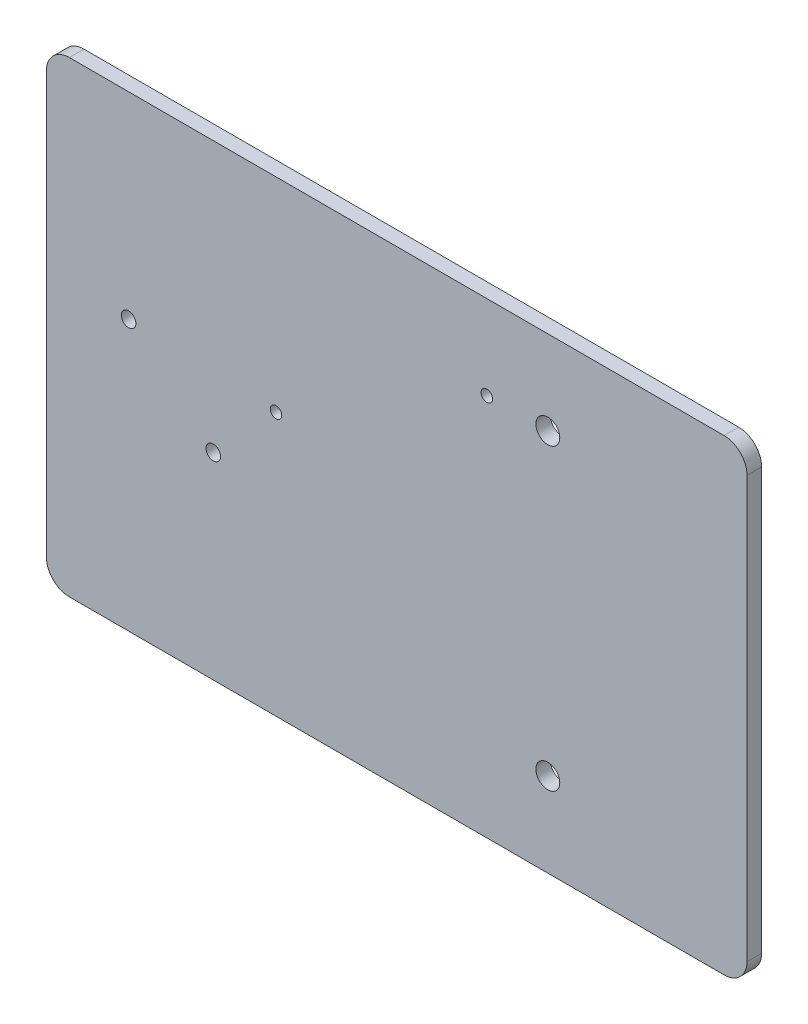
from build123d import *

# Parameters (mm, degrees)
SKETCH1_W           = 152.4
SKETCH1_H           = 101.6
BOSS_EXTRUDE1_DEPTH = 3.175
CUT_EXTRUDE1_REACH  = 5.175
SKETCH2_R           = 2.6
SKETCH2_R_2         = 1.25
SKETCH2_R_3         = 1.5875
FILLET1_R           = 5


with BuildPart() as part:
    # Sketch1 → Boss-Extrude1 (new body)
    with BuildSketch(Plane.XY):
        with Locations((76.2, 50.8)):
            Rectangle(SKETCH1_W, SKETCH1_H)
    extrude(amount=BOSS_EXTRUDE1_DEPTH)

    # Sketch2 → Cut-Extrude1 (cut, up to next)
    with BuildSketch(Plane.XY.offset(3.175), mode=Mode.PRIVATE) as cut_extrude1_sk1:
        with Locations((109.06828742, 18.3)):
            Circle(SKETCH2_R)
    cut_extrude1_tool1 = extrude(cut_extrude1_sk1.sketch, amount=-CUT_EXTRUDE1_REACH, mode=Mode.PRIVATE) & part.part
    add(cut_extrude1_tool1.solids().sort_by_distance((109.068287, 18.3, 3.175))[0], mode=Mode.SUBTRACT)
    # Sketch2 → Cut-Extrude1 (cut, up to next)
    with BuildSketch(Plane.XY.offset(3.175), mode=Mode.PRIVATE) as cut_extrude1_sk2:
        with Locations((109.06828742, 83.3)):
            Circle(SKETCH2_R)
    cut_extrude1_tool2 = extrude(cut_extrude1_sk2.sketch, amount=-CUT_EXTRUDE1_REACH, mode=Mode.PRIVATE) & part.part
    add(cut_extrude1_tool2.solids().sort_by_distance((109.068287, 83.3, 3.175))[0], mode=Mode.SUBTRACT)
    # Sketch2 → Cut-Extrude1 (cut, up to next)
    with BuildSketch(Plane.XY.offset(3.175), mode=Mode.PRIVATE) as cut_extrude1_sk3:
        with Locations((95.79724118, 83.3)):
            Circle(SKETCH2_R_2)
    cut_extrude1_tool3 = extrude(cut_extrude1_sk3.sketch, amount=-CUT_EXTRUDE1_REACH, mode=Mode.PRIVATE) & part.part
    add(cut_extrude1_tool3.solids().sort_by_distance((95.797241, 83.3, 3.175))[0], mode=Mode.SUBTRACT)
    # Sketch2 → Cut-Extrude1 (cut, up to next)
    with BuildSketch(Plane.XY.offset(3.175), mode=Mode.PRIVATE) as cut_extrude1_sk4:
        with Locations((49.94724118, 57.26)):
            Circle(SKETCH2_R_2)
    cut_extrude1_tool4 = extrude(cut_extrude1_sk4.sketch, amount=-CUT_EXTRUDE1_REACH, mode=Mode.PRIVATE) & part.part
    add(cut_extrude1_tool4.solids().sort_by_distance((49.947241, 57.26, 3.175))[0], mode=Mode.SUBTRACT)
    # Sketch2 → Cut-Extrude1 (cut, up to next)
    with BuildSketch(Plane.XY.offset(3.175), mode=Mode.PRIVATE) as cut_extrude1_sk5:
        with Locations((17.879257387, 58.74)):
            Circle(SKETCH2_R_3)
    cut_extrude1_tool5 = extrude(cut_extrude1_sk5.sketch, amount=-CUT_EXTRUDE1_REACH, mode=Mode.PRIVATE) & part.part
    add(cut_extrude1_tool5.solids().sort_by_distance((17.879257, 58.74, 3.175))[0], mode=Mode.SUBTRACT)
    # Sketch2 → Cut-Extrude1 (cut, up to next)
    with BuildSketch(Plane.XY.offset(3.175), mode=Mode.PRIVATE) as cut_extrude1_sk6:
        with Locations((36.299257387, 42.86)):
            Circle(SKETCH2_R_3)
    cut_extrude1_tool6 = extrude(cut_extrude1_sk6.sketch, amount=-CUT_EXTRUDE1_REACH, mode=Mode.PRIVATE) & part.part
    add(cut_extrude1_tool6.solids().sort_by_distance((36.299257, 42.86, 3.175))[0], mode=Mode.SUBTRACT)

    # Fillet1
    fillet1_edges = [part.edges().sort_by_distance(p)[0] for p in [
        (0, 101.6, 1.5875),
        (152.4, 101.6, 1.5875),
        (152.4, 0, 1.5875),
        (0, 0, 1.5875),
    ]]
    fillet(fillet1_edges, radius=FILLET1_R)


solid = part.part
